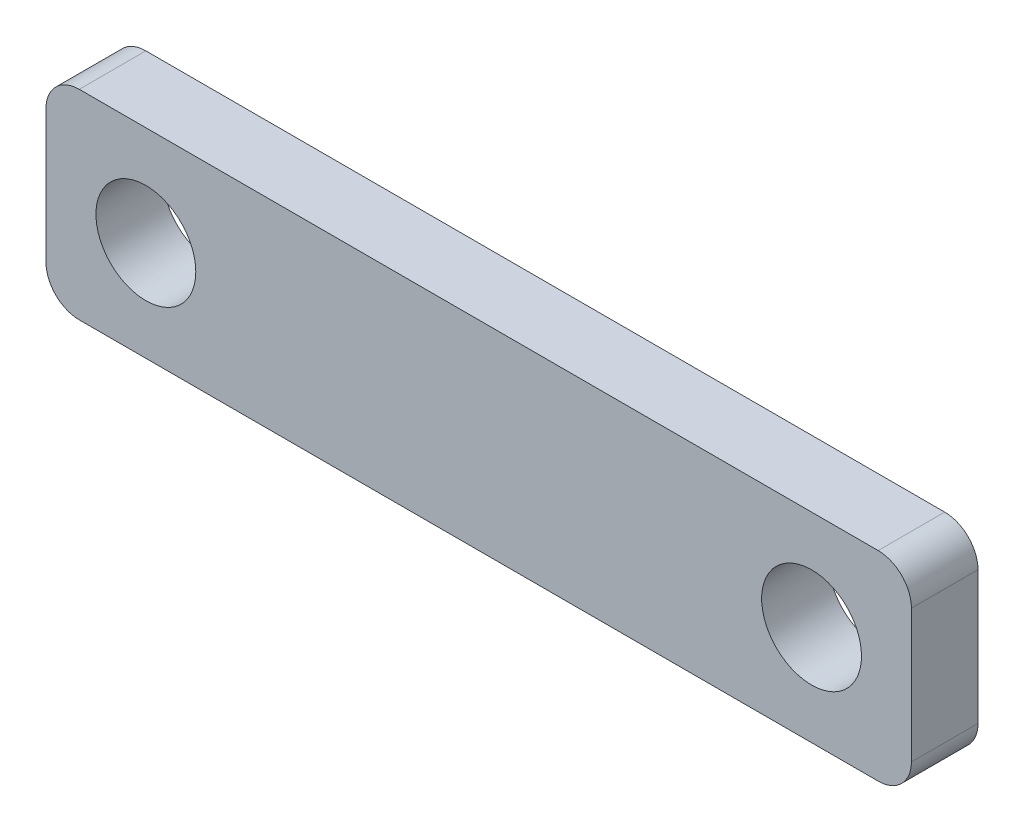
from build123d import *

# Parameters (mm, degrees)
ESQUISSE1_W        = 26
ESQUISSE1_H        = 6
ESQUISSE1_R        = 1.5
BOSS_EXTRU_1_DEPTH = 2
CONG_1_R           = 1


with BuildPart() as part:
    # Esquisse1 → Boss.-Extru.1 (new body)
    with BuildSketch(Plane.XY):
        Rectangle(ESQUISSE1_W, ESQUISSE1_H)
        with Locations((10, 0)):
            Circle(ESQUISSE1_R, mode=Mode.SUBTRACT)
        with Locations((-10, 0)):
            Circle(ESQUISSE1_R, mode=Mode.SUBTRACT)
    extrude(amount=BOSS_EXTRU_1_DEPTH)

    # Congé1
    cong_1_edges = [part.edges().sort_by_distance(p)[0] for p in [
        (13, -3, 1),
        (-13, -3, 1),
        (-13, 3, 1),
        (13, 3, 1),
    ]]
    fillet(cong_1_edges, radius=CONG_1_R)


solid = part.part
